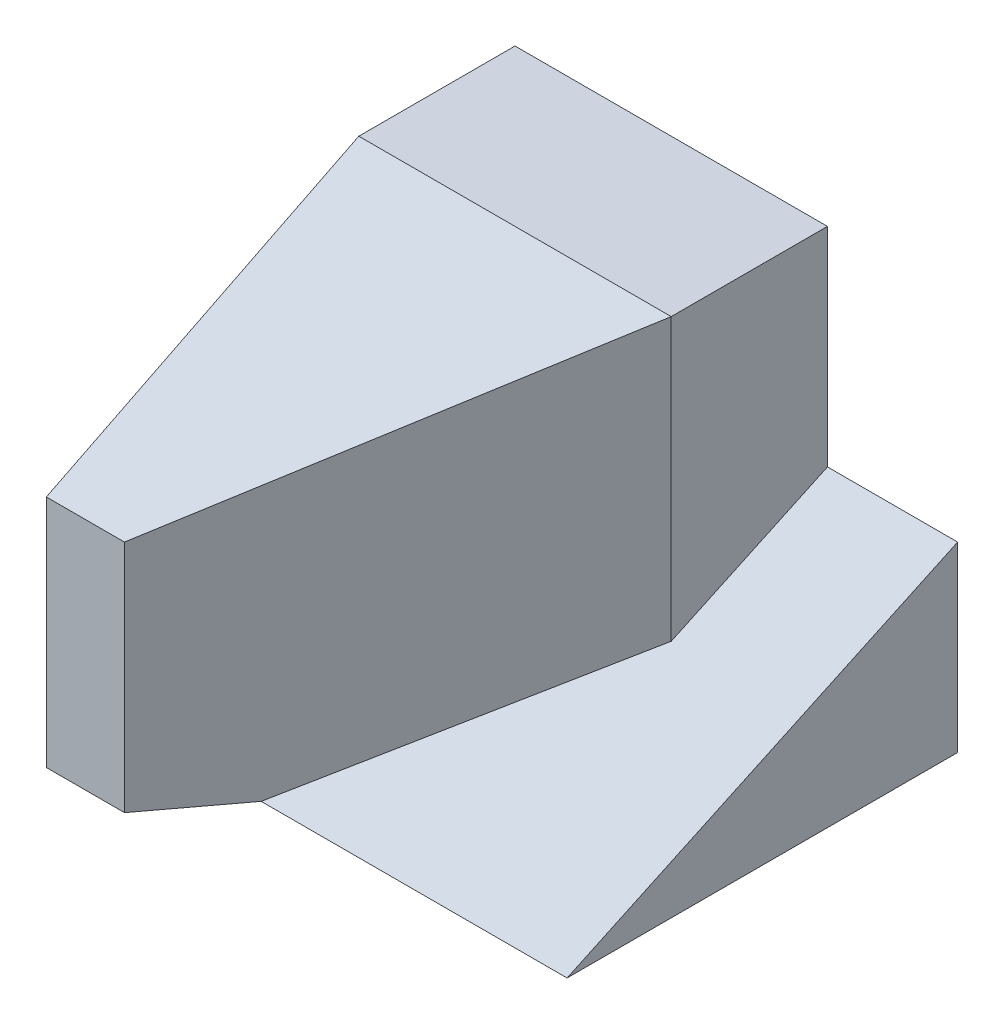
from build123d import *

# Parameters (mm, degrees)
SKETCH1_W           = 60
SKETCH1_H           = 90
EXTRUDE1_DEPTH      = 75
EXTRUDE2_DEPTH      = 61
EXTRUDE3_DEPTH      = 76
EXTRUDE4_DEPTH      = 25
EXTRUDE4_DEPTH_BACK = 55


with BuildPart() as part:
    # Sketch1 → Extrude1 (new body)
    with BuildSketch(Plane(origin=(0, 0, 0), x_dir=(1, 0, 0), z_dir=(0, 1, 0))):
        with Locations((30, 45)):
            Rectangle(SKETCH1_W, SKETCH1_H)
    extrude(amount=EXTRUDE1_DEPTH)

    # Sketch2 → Extrude2 (cut, through all)
    with BuildSketch(Plane(origin=(60, 0, 0), x_dir=(0, 0, -1), z_dir=(1, 0, 0))):
        Polygon((60, 75), (0, 45), (0, 75), align=None)
    extrude(amount=-EXTRUDE2_DEPTH, mode=Mode.SUBTRACT)

    # Sketch3 → Extrude3 (cut, through all)
    with BuildSketch(Plane(origin=(0, 75, 0), x_dir=(1, 0, 0), z_dir=(0, 1, 0))):
        Polygon((60, 60), (15, 0), (60, 0), align=None)
    extrude(amount=-EXTRUDE3_DEPTH, mode=Mode.SUBTRACT)

    # Sketch4 → Extrude4 (add, two sides)
    with BuildSketch(Plane(origin=(60, 0, 0), x_dir=(0, 0, -1), z_dir=(1, 0, 0))) as extrude4_sk:
        Polygon((90, 0), (15, 0), (90, 35), align=None)
    extrude(amount=EXTRUDE4_DEPTH)
    extrude(extrude4_sk.sketch, amount=-EXTRUDE4_DEPTH_BACK)


solid = part.part
